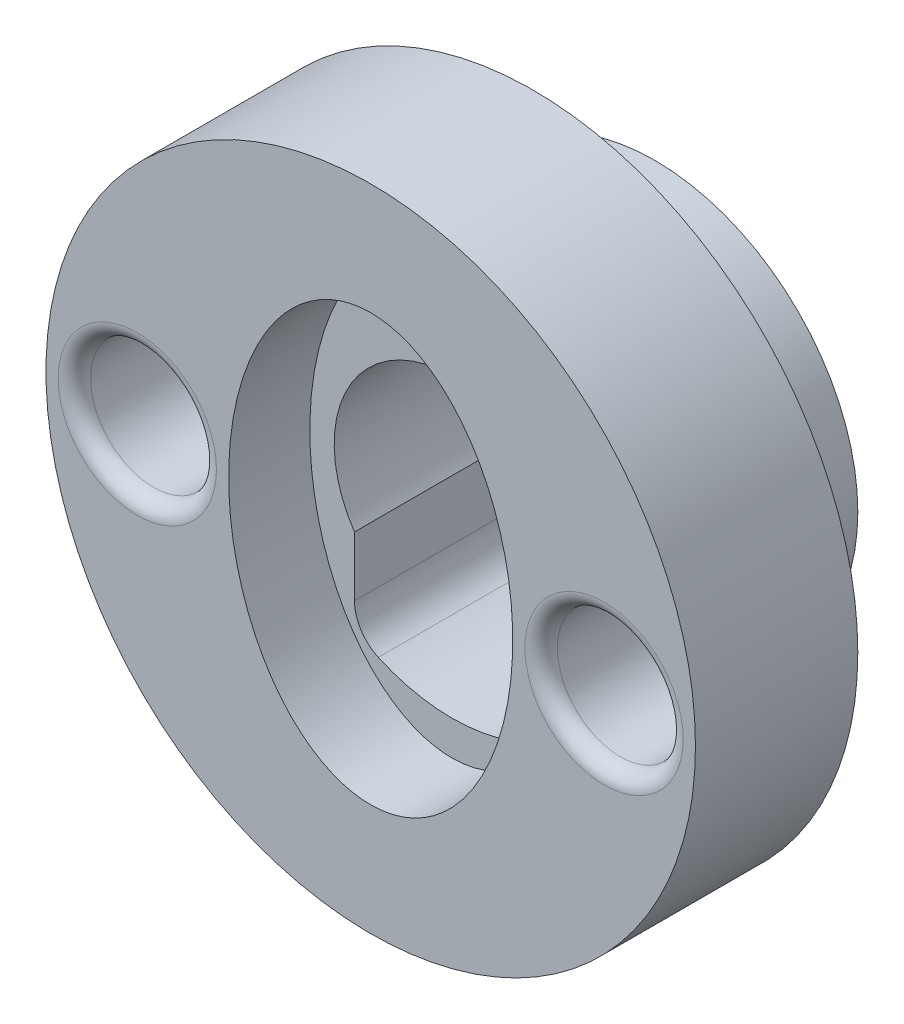
from build123d import *

# Parameters (mm, degrees)
SKETCH1_R           = 5
SKETCH1_R_2         = 1
BOSS_EXTRUDE1_DEPTH = 3
SKETCH2_R           = 8
BOSS_EXTRUDE2_DEPTH = 4
SKETCH4_R           = 1
CUT_EXTRUDE2_DEPTH  = 8
SKETCH3_RX          = 5.25
SKETCH3_RY          = 3.5
CUT_EXTRUDE1_DEPTH  = 2
SKETCH10_R          = 1
CUT_EXTRUDE5_DEPTH  = 7
SKETCH9_R           = 1.55
CUT_EXTRUDE4_DEPTH  = 3.5
CUT_EXTRUDE9_DEPTH  = 10
FILLET3_R           = 1
FILLET1_R           = 0.4


with BuildPart() as part:
    # Sketch1 → Boss-Extrude1 (new body)
    with BuildSketch(Plane.XY):
        Circle(SKETCH1_R)
        Circle(SKETCH1_R_2, mode=Mode.SUBTRACT)
    extrude(amount=BOSS_EXTRUDE1_DEPTH)

    # Sketch2 → Boss-Extrude2 (add)
    with BuildSketch(Plane.XY.offset(3)):
        Circle(SKETCH2_R)
    extrude(amount=BOSS_EXTRUDE2_DEPTH)

    # Sketch4 → Cut-Extrude2 (cut)
    with BuildSketch(Plane(origin=(0, 0, 3), x_dir=(-1, 0, 0), z_dir=(0, 0, -1))):
        with Locations(Location((0, 0, 0), (0, 0, 180))):
            Circle(SKETCH4_R)
    extrude(amount=-CUT_EXTRUDE2_DEPTH, mode=Mode.SUBTRACT)

    # Sketch3 → Cut-Extrude1 (cut)
    with BuildSketch(Plane.XY.offset(7)):
        with Locations(Location((0, 0), (0, 0, -90))):
            Ellipse(SKETCH3_RX, SKETCH3_RY)
    extrude(amount=-CUT_EXTRUDE1_DEPTH, mode=Mode.SUBTRACT)

    # Sketch10 → Cut-Extrude5 (cut)
    with BuildSketch(Plane(origin=(0, 0, 0), x_dir=(-1, 0, 0), z_dir=(0, 0, -1))):
        with BuildLine():
            Line((-2.25, -1.58113883), (-2.25, -3.605551275))
            ThreePointArc((-2.25, -3.605551275), (0, -4.25), (2.25, -3.605551275))
            Line((2.25, -3.605551275), (2.25, -1.58113883))
            ThreePointArc((2.25, -1.58113883), (0, 2.75), (-2.25, -1.58113883))
        make_face()
        Circle(SKETCH10_R, mode=Mode.SUBTRACT)
    extrude(amount=-CUT_EXTRUDE5_DEPTH, mode=Mode.SUBTRACT)

    # Sketch9 → Cut-Extrude4 (cut)
    with BuildSketch(Plane.XY.offset(7)):
        with Locations((-5.75, 0)):
            Circle(SKETCH9_R)
        with Locations((5.75, 0)):
            Circle(SKETCH9_R)
    extrude(amount=-CUT_EXTRUDE4_DEPTH, mode=Mode.SUBTRACT)

    # Sketch14 → Cut-Extrude9 (cut)
    with BuildSketch(Plane.XY.offset(5)):
        with BuildLine():
            Line((-2.4, -3.687817783), (-2.4, -1.62788206))
            ThreePointArc((-2.4, -1.62788206), (0, 2.9), (2.4, -1.62788206))
            Line((2.4, -1.62788206), (2.4, -3.687817783))
            ThreePointArc((2.4, -3.687817783), (0, -4.4), (-2.4, -3.687817783))
        make_face()
        with BuildLine():
            Line((2.25, -3.605551275), (2.25, -1.58113883))
            ThreePointArc((2.25, -1.58113883), (0, 2.75), (-2.25, -1.58113883))
            Line((-2.25, -1.58113883), (-2.25, -3.605551275))
            ThreePointArc((-2.25, -3.605551275), (0, -4.25), (2.25, -3.605551275))
        make_face(mode=Mode.SUBTRACT)
    extrude(amount=-CUT_EXTRUDE9_DEPTH, mode=Mode.SUBTRACT)

    # Fillet3
    fillet3_edges = [part.edges().sort_by_distance(p)[0] for p in [
        (2.4, -3.687817783, 2.5),
        (-2.4, -3.687817783, 2.5),
    ]]
    fillet(fillet3_edges, radius=FILLET3_R)

    # Fillet1
    fillet1_edges = [part.edges().sort_by_distance(p)[0] for p in [
        (-7.3, 0, 7),
        (4.2, 0, 7),
    ]]
    fillet(fillet1_edges, radius=FILLET1_R)


solid = part.part
